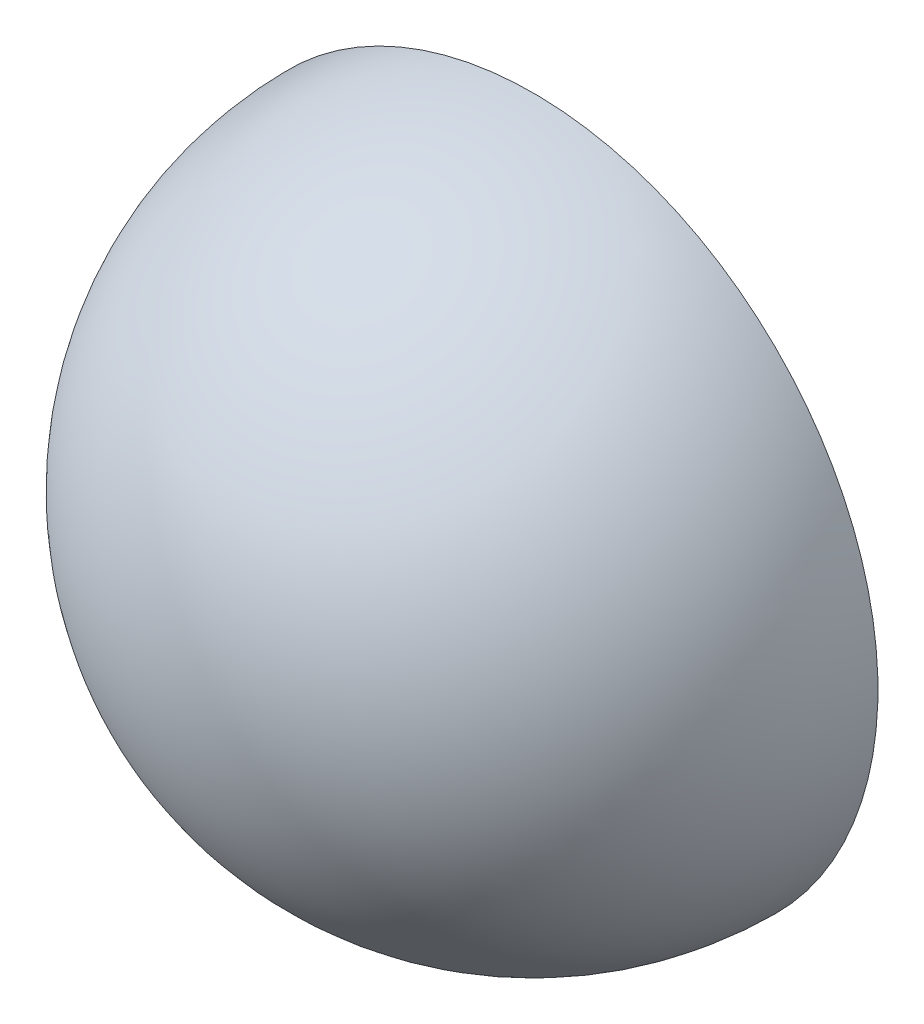
from build123d import *

# Parameters (mm, degrees)
REVOLVE1_ANGLE = 180


with BuildPart() as part:
    # Sketch1 → Revolve1 (revolve)
    with BuildSketch(Plane.XY):
        with BuildLine():
            Line((-120, 0), (-119, 0))
            ThreePointArc((-119, 0), (-60, 59), (-1, 0))
            Line((-1, 0), (0, 0))
            ThreePointArc((0, 0), (-60, 60), (-120, 0))
        make_face()
    revolve(axis=Axis((-119, 0, 0), (1, 0, 0)), revolution_arc=REVOLVE1_ANGLE)


solid = part.part
